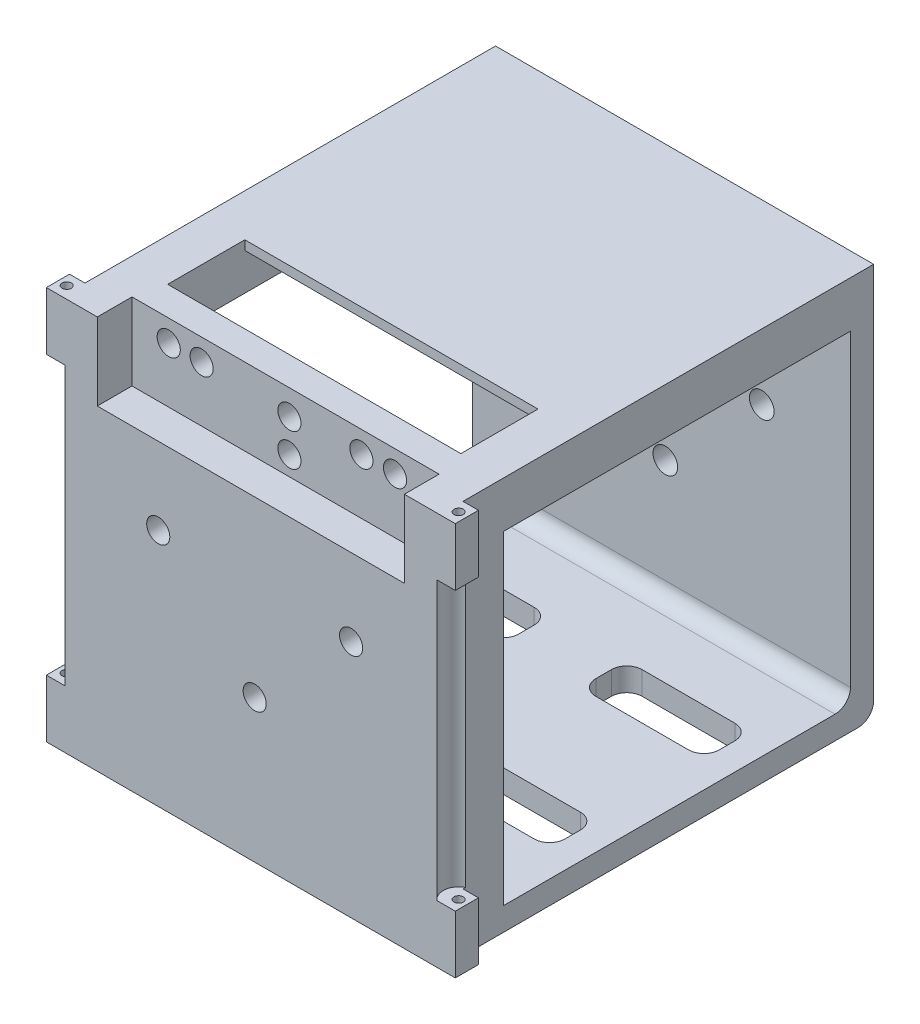
from build123d import *

# Parameters (mm, degrees)
SKETCH_1_W          = 49
SKETCH_1_H          = 51
SKETCH_1_R          = 6
SKETCH_1_R_2        = 1.6
EXTRUDE_1_DEPTH     = 3
SKETCH_2_W          = 49
SKETCH_2_H          = 45
SKETCH_2_W_2        = 16
SKETCH_2_H_2        = 6
EXTRUDE_2_DEPTH     = 3
SKETCH_3_W          = 49
SKETCH_3_H          = 51
SKETCH_3_R          = 1.5
EXTRUDE_3_DEPTH     = 8.22
FILLET_2_R          = 2
FILLET_3_R          = 2
FILLET_4_R          = 2
FILLET_5_R          = 2
FILLET_6_R          = 2
SKETCH_4_W          = 2
SKETCH_4_H          = 3
EXTRUDE_4_DEPTH     = 51
SKETCH_5_W          = 5.5
SKETCH_5_H          = 45.037473363
EXTRUDE_5_DEPTH     = 6
MM_3_D              = 3
MM_3_DEPTH          = 8.22
SKETCH_12_W         = 39.8
SKETCH_12_H         = 4.5
CUT_EXTRUDE_6_DEPTH = 10
SKETCH_13_W         = 2
SKETCH_13_H         = 36
CUT_EXTRUDE_7_DEPTH = 57.22
SKETCH_14_R         = 0.6
CUT_EXTRUDE_8_DEPTH = 52
SKETCH_15_R         = 2
CUT_EXTRUDE_9_DEPTH = 36
SKETCH_16_W         = 38
SKETCH_16_H         = 1.2
EXTRUDE_6_DEPTH     = 35


with BuildPart() as part:
    # 草图1 → 凸台-拉伸1 (new body)
    with BuildSketch(Plane.XY):
        with Locations((-0.5, -5.5)):
            Rectangle(SKETCH_1_W, SKETCH_1_H)
        Circle(SKETCH_1_R, mode=Mode.SUBTRACT)
        with Locations((12.5, 0)):
            Circle(SKETCH_1_R_2, mode=Mode.SUBTRACT)
        with Locations((-12.5, 0)):
            Circle(SKETCH_1_R_2, mode=Mode.SUBTRACT)
        with Locations((0, 12.5)):
            Circle(SKETCH_1_R_2, mode=Mode.SUBTRACT)
        with Locations((0, -12.5)):
            Circle(SKETCH_1_R_2, mode=Mode.SUBTRACT)
    extrude(amount=EXTRUDE_1_DEPTH)

    # 草图2 → 凸台-拉伸2 (add)
    with BuildSketch(Plane.XZ.offset(31)):
        with Locations((-0.5, 25.5)):
            Rectangle(SKETCH_2_W, SKETCH_2_H)
        with Locations((-13.5, 15.5)):
            Rectangle(SKETCH_2_W_2, SKETCH_2_H_2, mode=Mode.SUBTRACT)
        with Locations((12.5, 15.5)):
            Rectangle(SKETCH_2_W_2, SKETCH_2_H_2, mode=Mode.SUBTRACT)
        with Locations((-13.5, 35.5)):
            Rectangle(SKETCH_2_W_2, SKETCH_2_H_2, mode=Mode.SUBTRACT)
        with Locations((12.5, 35.5)):
            Rectangle(SKETCH_2_W_2, SKETCH_2_H_2, mode=Mode.SUBTRACT)
    extrude(amount=-EXTRUDE_2_DEPTH)

    # 草图3 → 凸台-拉伸3 (add)
    with BuildSketch(Plane.XY.offset(48)):
        with Locations((-0.5, -5.5)):
            Rectangle(SKETCH_3_W, SKETCH_3_H)
        with Locations((-12.5, 0)):
            Circle(SKETCH_3_R, mode=Mode.SUBTRACT)
        with Locations((12.5, 0)):
            Circle(SKETCH_3_R, mode=Mode.SUBTRACT)
        with Locations((0, -12.5)):
            Circle(SKETCH_3_R, mode=Mode.SUBTRACT)
        with Locations((0, 12.5)):
            Circle(SKETCH_3_R, mode=Mode.SUBTRACT)
        with Locations((0, 16.75)):
            Circle(SKETCH_3_R, mode=Mode.SUBTRACT)
    extrude(amount=EXTRUDE_3_DEPTH)

    # 圆角2
    fillet_2_edges = [part.edges().sort_by_distance(p)[0] for p in [
        (-5.5, -29.5, 12.5),
    ]]
    fillet(fillet_2_edges, radius=FILLET_2_R)

    # 圆角3
    fillet_3_edges = [part.edges().sort_by_distance(p)[0] for p in [
        (-21.5, -29.5, 12.5),
        (-21.5, -29.5, 18.5),
        (-5.5, -29.5, 18.5),
    ]]
    fillet(fillet_3_edges, radius=FILLET_3_R)

    # 圆角4
    fillet_4_edges = [part.edges().sort_by_distance(p)[0] for p in [
        (20.5, -29.5, 18.5),
        (20.5, -29.5, 12.5),
        (4.5, -29.5, 12.5),
        (4.5, -29.5, 18.5),
        (-21.5, -29.5, 32.5),
        (-21.5, -29.5, 38.5),
        (-5.5, -29.5, 38.5),
        (-5.5, -29.5, 32.5),
        (4.5, -29.5, 32.5),
        (4.5, -29.5, 38.5),
        (20.5, -29.5, 38.5),
        (20.5, -29.5, 32.5),
    ]]
    fillet(fillet_4_edges, radius=FILLET_4_R)

    # 圆角5
    fillet_5_edges = [part.edges().sort_by_distance(p)[0] for p in [
        (-0.5, -28, 3),
    ]]
    fillet(fillet_5_edges, radius=FILLET_5_R)

    # 圆角6
    fillet_6_edges = [part.edges().sort_by_distance(p)[0] for p in [
        (-0.5, -31, 0),
    ]]
    fillet(fillet_6_edges, radius=FILLET_6_R)

    # 草图4 → 凸台-拉伸4 (add)
    with BuildSketch(Plane(origin=(0, -31, 0), x_dir=(-1, 0, 0), z_dir=(0, -1, 0))):
        with Locations((-25, -54.72)):
            Rectangle(SKETCH_4_W, SKETCH_4_H)
        with Locations((26, -54.72)):
            Rectangle(SKETCH_4_W, SKETCH_4_H)
    extrude(amount=-EXTRUDE_4_DEPTH)

    # 草图5 → 凸台-拉伸5 (add)
    with BuildSketch(Plane(origin=(0, 20, 0), x_dir=(1, 0, 0), z_dir=(0, 1, 0))):
        with Locations((-22.25, -25.481263319)):
            Rectangle(SKETCH_5_W, SKETCH_5_H)
        with Locations((21.25, -25.481263319)):
            Rectangle(SKETCH_5_W, SKETCH_5_H)
    extrude(amount=-EXTRUDE_5_DEPTH)

    # 大小mm 暗销孔3
    with Locations(Plane(origin=(0, 0, 48), x_dir=(-1, 0, 0), z_dir=(0, 0, -1))):
        with Locations((15.643749591, 17.172263121), (11.37731054, 17.172263121), (-13.686969003, 17.172263121), (-9.332744424, 17.172263121)):
            Hole(MM_3_D / 2, depth=MM_3_DEPTH)

    # 草图12 → 切除-拉伸6 (cut)
    with BuildSketch(Plane(origin=(0, 20, 0), x_dir=(1, 0, 0), z_dir=(0, 1, 0))):
        with Locations((-0.5, -53.97)):
            Rectangle(SKETCH_12_W, SKETCH_12_H)
    extrude(amount=-CUT_EXTRUDE_6_DEPTH, mode=Mode.SUBTRACT)

    # 草图13 → 切除-拉伸7 (cut, through all)
    with BuildSketch(Plane(origin=(0, 0, 0), x_dir=(-1, 0, 0), z_dir=(0, 0, -1))):
        with Locations((-25, -5.5)):
            Rectangle(SKETCH_13_W, SKETCH_13_H)
        with Locations((26, -5.5)):
            Rectangle(SKETCH_13_W, SKETCH_13_H)
    extrude(amount=-CUT_EXTRUDE_7_DEPTH, mode=Mode.SUBTRACT)

    # 草图14 → 切除-拉伸8 (cut, through all)
    with BuildSketch(Plane(origin=(0, 20, 0), x_dir=(1, 0, 0), z_dir=(0, 1, 0))):
        with Locations((24.9, -54.686530392)):
            Circle(SKETCH_14_R)
        with Locations((-25.9, -54.686530392)):
            Circle(SKETCH_14_R)
    extrude(amount=-CUT_EXTRUDE_8_DEPTH, mode=Mode.SUBTRACT)

    # 草图15 → 切除-拉伸9 (cut)
    with BuildSketch(Plane.XZ.offset(-12.5)):
        with Locations((24.9, 54.686530392)):
            Circle(SKETCH_15_R)
        with Locations((-25.9, 54.686530392)):
            Circle(SKETCH_15_R)
    extrude(amount=CUT_EXTRUDE_9_DEPTH, mode=Mode.SUBTRACT)

    # 草图16 → 凸台-拉伸6 (add)
    with BuildSketch(Plane.XY.offset(3)):
        with Locations((-0.5, 19.4)):
            Rectangle(SKETCH_16_W, SKETCH_16_H)
    extrude(amount=EXTRUDE_6_DEPTH)


solid = part.part
